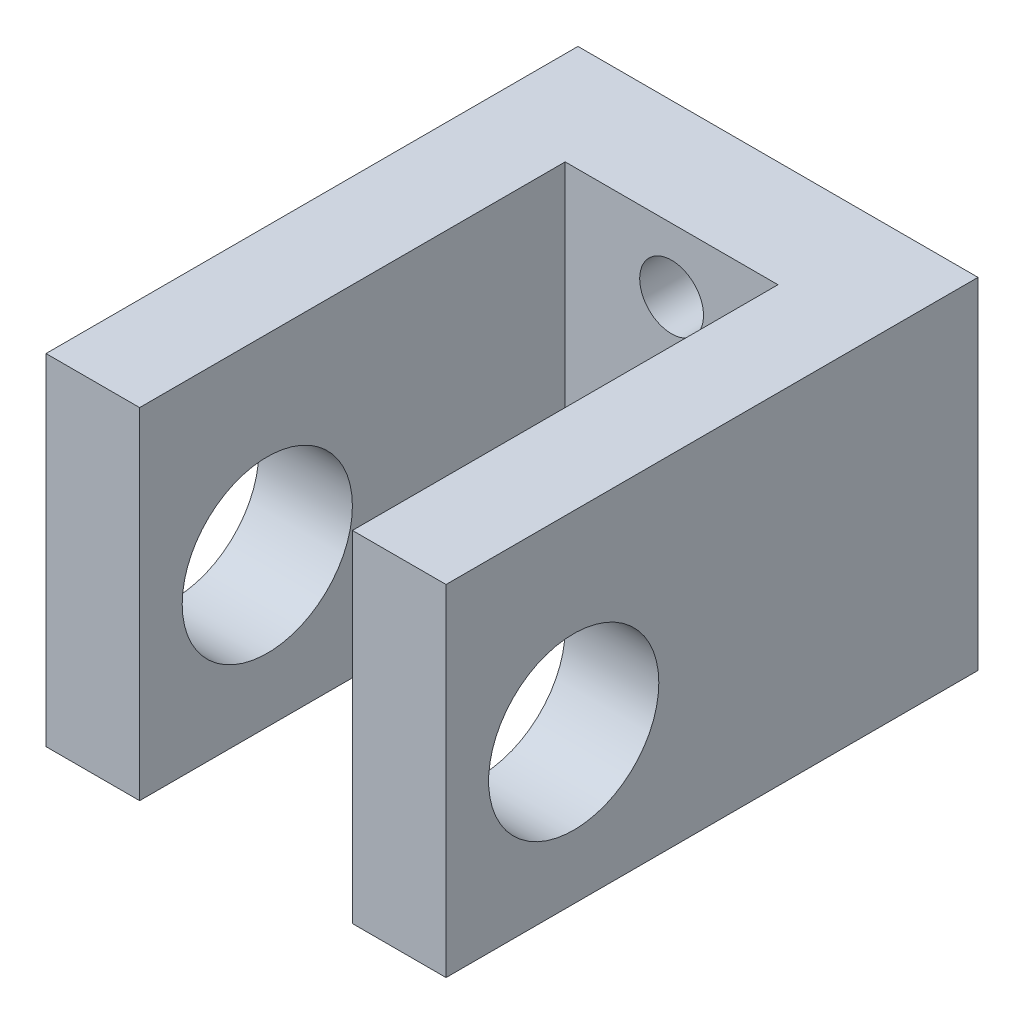
from build123d import *

# Parameters (mm, degrees)
BOSS_EXTRUDE1_DEPTH = 16
SKETCH2_R           = 4
CUT_EXTRUDE1_DEPTH  = 19.8
SKETCH3_R           = 1.5
CUT_EXTRUDE2_DEPTH  = 26


with BuildPart() as part:
    # Sketch1 → Boss-Extrude1 (new body)
    with BuildSketch(Plane(origin=(0, 0, 0), x_dir=(1, 0, 0), z_dir=(0, 1, 0))):
        Polygon((-9.4, 0), (9.4, 0), (9.4, -25), (5, -25), (5, -5), (-5, -5), (-5, -25), (-9.4, -25), align=None)
    extrude(amount=BOSS_EXTRUDE1_DEPTH)

    # Sketch2 → Cut-Extrude1 (cut, through all)
    with BuildSketch(Plane(origin=(9.4, 0, 0), x_dir=(0, 0, -1), z_dir=(1, 0, 0))):
        with Locations((-19, 7)):
            Circle(SKETCH2_R)
    extrude(amount=-CUT_EXTRUDE1_DEPTH, mode=Mode.SUBTRACT)

    # Sketch3 → Cut-Extrude2 (cut, through all)
    with BuildSketch(Plane(origin=(0, 0, 0), x_dir=(-1, 0, 0), z_dir=(0, 0, -1))):
        with Locations((0, 13)):
            Circle(SKETCH3_R)
        with Locations((0, 3)):
            Circle(SKETCH3_R)
    extrude(amount=-CUT_EXTRUDE2_DEPTH, mode=Mode.SUBTRACT)


solid = part.part
